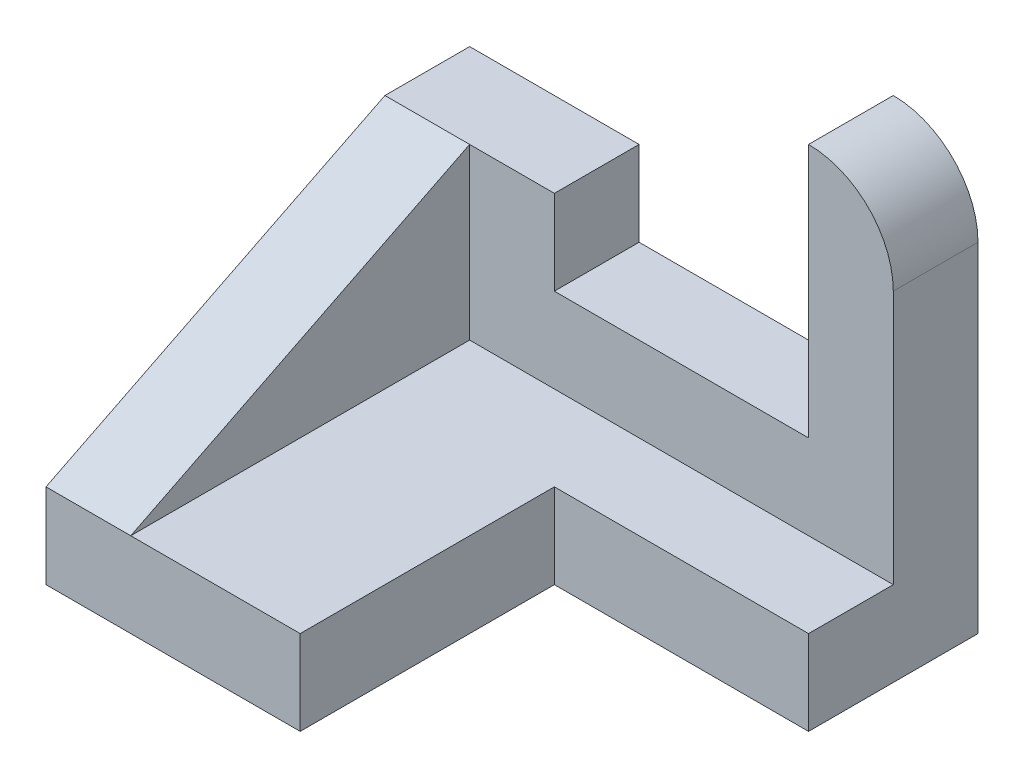
from build123d import *

# Parameters (mm, degrees)
BOSS_EXTRUDE1_DEPTH     = 1270
SKETCH1_5_W             = 762
SKETCH1_5_H             = 254
BOSS_EXTRUDE2_DEPTH     = 508
BOSS_EXTRUDE3_DEPTH     = 254
SKETCH1_7_W             = 254
SKETCH1_7_H             = 508
BOSS_EXTRUDE4_DEPTH     = 1270
CUT_EXTRUDE1_DEPTH      = 254
CUT_EXTRUDE1_DEPTH_BACK = 255


with BuildPart() as part:
    # Sketch1 → Boss-Extrude1 (new body)
    with BuildSketch(Plane.XY):
        Polygon((0, 254), (0, 0), (762, 0), (762, 254), (254, 254), align=None)
    extrude(amount=BOSS_EXTRUDE1_DEPTH)

    # Sketch1_5 → Boss-Extrude2 (add)
    with BuildSketch(Plane.XY):
        with Locations((1143, 127)):
            Rectangle(SKETCH1_5_W, SKETCH1_5_H)
    extrude(amount=BOSS_EXTRUDE2_DEPTH)

    # Sketch1_6 → Boss-Extrude3 (add)
    with BuildSketch(Plane.XY):
        with BuildLine():
            Line((254, 762), (254, 254))
            Line((254, 254), (762, 254))
            Line((762, 254), (1524, 254))
            Line((1524, 254), (1524, 1015.999999044))
            ThreePointArc((1524, 1015.999999044), (1449.605122957, 1195.605122281), (1270, 1270))
            Line((1270, 1270), (1270, 508))
            Line((1270, 508), (508, 508))
            Line((508, 508), (508, 762))
            Line((508, 762), (254, 762))
        make_face()
    extrude(amount=BOSS_EXTRUDE3_DEPTH)

    # Sketch1_7 → Boss-Extrude4 (add)
    with BuildSketch(Plane.XY):
        with Locations((127, 508)):
            Rectangle(SKETCH1_7_W, SKETCH1_7_H)
    extrude(amount=BOSS_EXTRUDE4_DEPTH)

    # Sketch2 → Cut-Extrude1 (cut, two sides)
    with BuildSketch(Plane(origin=(254, 0, 0), x_dir=(0, 0, -1), z_dir=(1, 0, 0))) as cut_extrude1_sk:
        Polygon((2664.325511968, 2221.162755984), (-254, 762), (-1270, 254), (-4188.325511968, -1205.162755984), (-7106.651023936, 4631.488267952), (-254, 8057.813779919), align=None)
    extrude(amount=CUT_EXTRUDE1_DEPTH, mode=Mode.SUBTRACT)
    extrude(cut_extrude1_sk.sketch, amount=-CUT_EXTRUDE1_DEPTH_BACK, mode=Mode.SUBTRACT)


solid = part.part
